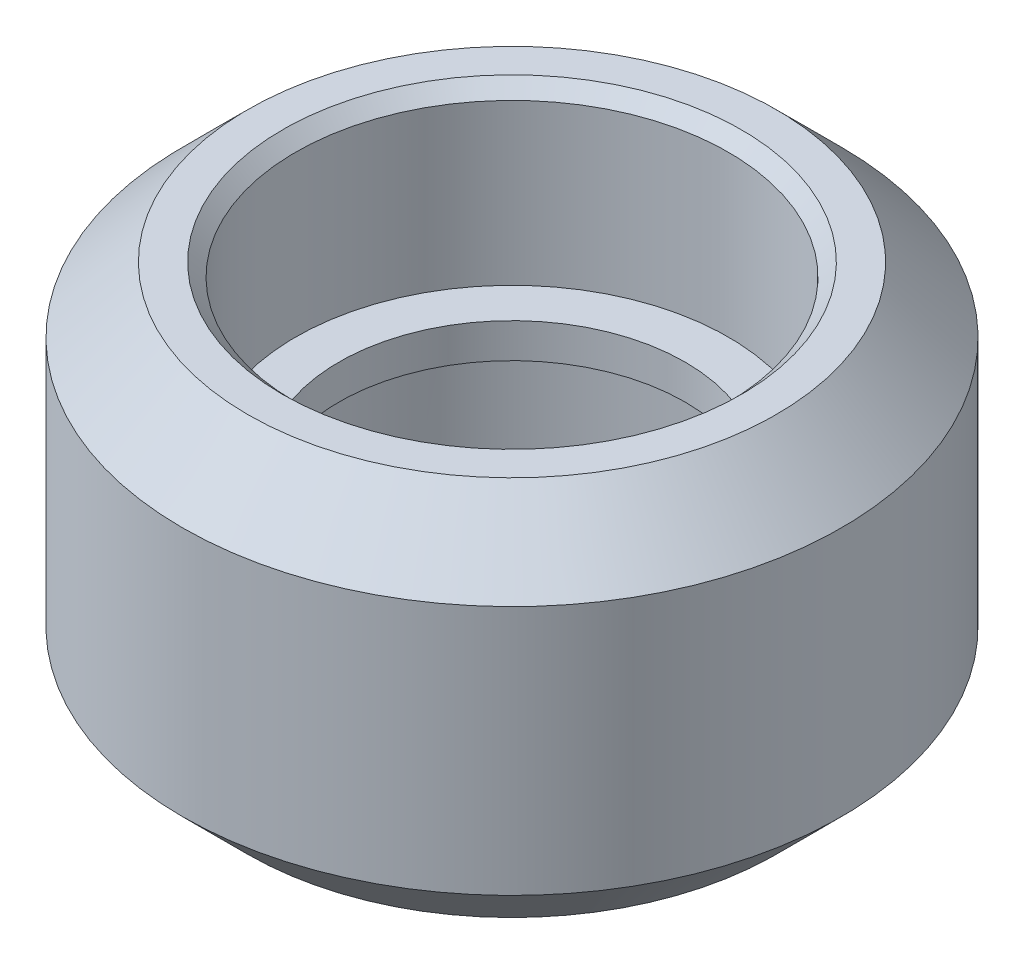
from build123d import *

# Parameters (mm, degrees)
SKETCH1_R           = 7.615
SKETCH1_R_2         = 4
BOSS_EXTRUDE1_DEPTH = 8.8
SKETCH2_R           = 5
CUT_EXTRUDE1_DEPTH  = 4
SKETCH3_R           = 5
CUT_EXTRUDE2_DEPTH  = 4
CHAMFER1_SIZE       = 0.3
CHAMFER2_SIZE       = 1.51


with BuildPart() as part:
    # Sketch1 → Boss-Extrude1 (new body)
    with BuildSketch(Plane(origin=(0, 0, 0), x_dir=(1, 0, 0), z_dir=(0, 1, 0))):
        Circle(SKETCH1_R)
        Circle(SKETCH1_R_2, mode=Mode.SUBTRACT)
    extrude(amount=BOSS_EXTRUDE1_DEPTH)

    # Sketch2 → Cut-Extrude1 (cut)
    with BuildSketch(Plane(origin=(0, 8.8, 0), x_dir=(1, 0, 0), z_dir=(0, 1, 0))):
        Circle(SKETCH2_R)
    extrude(amount=-CUT_EXTRUDE1_DEPTH, mode=Mode.SUBTRACT)

    # Sketch3 → Cut-Extrude2 (cut)
    with BuildSketch(Plane.XZ):
        Circle(SKETCH3_R)
    extrude(amount=-CUT_EXTRUDE2_DEPTH, mode=Mode.SUBTRACT)

    # Chamfer1
    chamfer1_edges = [part.edges().sort_by_distance(p)[0] for p in [
        (-5, 8.8, 0),
        (-5, 0, 0),
    ]]
    chamfer(chamfer1_edges, length=CHAMFER1_SIZE)

    # Chamfer2
    chamfer2_edges = [part.edges().sort_by_distance(p)[0] for p in [
        (-7.615, 0, 0),
        (-7.615, 8.8, 0),
    ]]
    chamfer(chamfer2_edges, length=CHAMFER2_SIZE)


solid = part.part
